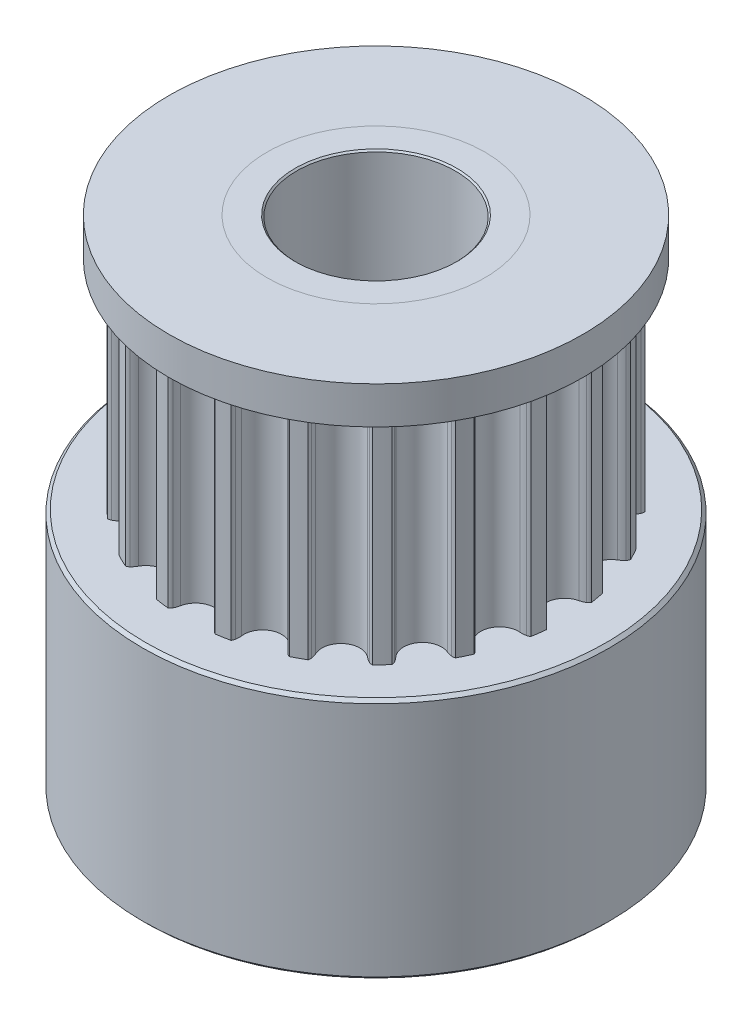
from build123d import *

# Parameters (mm, degrees)
P_IDAT_START            = 7.8
SKICA1_R                = 2.5
P_IDAT_VYSUNUT_M1_DEPTH = 7
SKICA2_R                = 3.5
SKICA2_R_2              = 2.5
P_IDAT_VYSUNUT_M2_DEPTH = 7.8
SKICA3_R                = 3.5
SKICA3_R_2              = 2.5
P_IDAT_VYSUNUT_M3_DEPTH = 1.2
SKICA5_R                = 7.5
SKICA5_R_2              = 3.5
P_IDAT_VYSUNUT_M4_DEPTH = 1.2
SKICA6_R                = 7.5
SKICA6_R_2              = 3.5
P_IDAT_VYSUNUT_M5_DEPTH = 7.8
ZKOSEN_1_SIZE           = 0.1
ZKOSEN_2_SIZE           = 0.1
ZKOSEN_3_SIZE           = 0.1
SKETCH8_OUTSIDE_W       = 22.314
SKETCH8_OUTSIDE_H       = 22.314
SKETCH8_OUTSIDE_R       = 6.65
CUT_EXTRUDE2_DEPTH      = 5
SKETCH19_R              = 1.5
CUT_EXTRUDE6_DEPTH      = 8
SKETCH20_R              = 1.5
CUT_EXTRUDE7_DEPTH      = 8
SKETCH21_R              = 2.55
CUT_EXTRUDE8_DEPTH      = 30


with BuildPart() as part:
    # Skica1 → Přidat vysunutím1 (new body)
    with BuildSketch(Plane(origin=(0, 0, 0), x_dir=(1, 0, 0), z_dir=(0, 1, 0)).offset(P_IDAT_START)):
        with BuildLine():
            ThreePointArc((-5.730143195, 1.098270155), (-5.09645097, 1.530497044), (-5.387174672, 2.240331989))
            ThreePointArc((-5.387174672, 2.240331989), (-5.468060657, 2.292707421), (-5.540463547, 2.356296335))
            ThreePointArc((-5.540463547, 2.356296335), (-5.573874331, 2.399596558), (-5.596043873, 2.44959357))
            ThreePointArc((-5.596043873, 2.44959357), (-5.50369925, 2.650567912), (-5.404139771, 2.848067596))
            ThreePointArc((-5.404139771, 2.848067596), (-5.351227535, 2.86190541), (-5.296542742, 2.862779021))
            ThreePointArc((-5.296542742, 2.862779021), (-5.201685094, 2.845815675), (-5.110305882, 2.815228615))
            ThreePointArc((-5.110305882, 2.815228615), (-4.374063308, 3.030479148), (-4.431206919, 3.795410862))
            ThreePointArc((-4.431206919, 3.795410862), (-4.491949163, 3.870218002), (-4.541158349, 3.953068377))
            ThreePointArc((-4.541158349, 3.953068377), (-4.559553388, 4.004573836), (-4.565187949, 4.058974585))
            ThreePointArc((-4.565187949, 4.058974585), (-4.415258506, 4.221576484), (-4.259541056, 4.378644275))
            ThreePointArc((-4.259541056, 4.378644275), (-4.204942409, 4.375454038), (-4.15266412, 4.359386362))
            ThreePointArc((-4.15266412, 4.359386362), (-4.067691098, 4.313940635), (-3.990236225, 4.256612884))
            ThreePointArc((-3.990236225, 4.256612884), (-3.223511854, 4.233816838), (-3.041481758, 4.978968476))
            ThreePointArc((-3.041481758, 4.978968476), (-3.076134388, 5.06888468), (-3.097332931, 5.162886543))
            ThreePointArc((-3.097332931, 5.162886543), (-3.09891159, 5.217555525), (-3.08745962, 5.271034888))
            ThreePointArc((-3.08745962, 5.271034888), (-2.894621497, 5.379347737), (-2.697988784, 5.480608745))
            ThreePointArc((-2.697988784, 5.480608745), (-2.647048223, 5.460702739), (-2.6022938, 5.429266591))
            ThreePointArc((-2.6022938, 5.429266591), (-2.535523156, 5.359787029), (-2.479574443, 5.281330225))
            ThreePointArc((-2.479574443, 5.281330225), (-1.7574206, 5.022719037), (-1.354035171, 5.675149965))
            ThreePointArc((-1.354035171, 5.675149965), (-1.359206146, 5.771373608), (-1.350318985, 5.867325402))
            ThreePointArc((-1.350318985, 5.867325402), (-1.334926735, 5.919806527), (-1.307509232, 5.967129569))
            ThreePointArc((-1.307509232, 5.967129569), (-1.090638767, 6.010550954), (-0.872338572, 6.046093045))
            ThreePointArc((-0.872338572, 6.046093045), (-0.830042514, 6.01141981), (-0.797192832, 5.967692379))
            ThreePointArc((-0.797192832, 5.967692379), (-0.755160541, 5.880980125), (-0.726194639, 5.789074167))
            ThreePointArc((-0.726194639, 5.789074167), (-0.119300773, 5.319962501), (0.465953812, 5.815808234))
            ThreePointArc((0.465953812, 5.815808234), (0.490770664, 5.908920276), (0.528873591, 5.997429571))
            ThreePointArc((0.528873591, 5.997429571), (0.55973005, 6.04258562), (0.600429269, 6.079120034))
            ThreePointArc((0.600429269, 6.079120034), (0.820103284, 6.053399565), (1.038702217, 6.019743632))
            ThreePointArc((1.038702217, 6.019743632), (1.06821354, 5.973697225), (1.085942924, 5.921958857))
            ThreePointArc((1.085942924, 5.921958857), (1.099122448, 5.826501911), (1.098270155, 5.730143195))
            ThreePointArc((1.098270155, 5.730143195), (1.530497044, 5.09645097), (2.240331989, 5.387174672))
            ThreePointArc((2.240331989, 5.387174672), (2.292707421, 5.468060657), (2.356296335, 5.540463547))
            ThreePointArc((2.356296335, 5.540463547), (2.399596558, 5.573874331), (2.44959357, 5.596043873))
            ThreePointArc((2.44959357, 5.596043873), (2.650567912, 5.50369925), (2.848067596, 5.404139771))
            ThreePointArc((2.848067596, 5.404139771), (2.86190541, 5.351227535), (2.862779021, 5.296542742))
            ThreePointArc((2.862779021, 5.296542742), (2.845815675, 5.201685094), (2.815228615, 5.110305882))
            ThreePointArc((2.815228615, 5.110305882), (3.030479148, 4.374063308), (3.795410862, 4.431206919))
            ThreePointArc((3.795410862, 4.431206919), (3.870218002, 4.491949163), (3.953068377, 4.541158349))
            ThreePointArc((3.953068377, 4.541158349), (4.004573836, 4.559553388), (4.058974585, 4.565187949))
            ThreePointArc((4.058974585, 4.565187949), (4.221576484, 4.415258506), (4.378644275, 4.259541056))
            ThreePointArc((4.378644275, 4.259541056), (4.375454038, 4.204942409), (4.359386362, 4.15266412))
            ThreePointArc((4.359386362, 4.15266412), (4.313940635, 4.067691098), (4.256612884, 3.990236225))
            ThreePointArc((4.256612884, 3.990236225), (4.233816838, 3.223511854), (4.978968476, 3.041481758))
            ThreePointArc((4.978968476, 3.041481758), (5.06888468, 3.076134388), (5.162886543, 3.097332931))
            ThreePointArc((5.162886543, 3.097332931), (5.217555525, 3.09891159), (5.271034888, 3.08745962))
            ThreePointArc((5.271034888, 3.08745962), (5.379347737, 2.894621497), (5.480608745, 2.697988784))
            ThreePointArc((5.480608745, 2.697988784), (5.460702739, 2.647048223), (5.429266591, 2.6022938))
            ThreePointArc((5.429266591, 2.6022938), (5.359787029, 2.535523156), (5.281330225, 2.479574443))
            ThreePointArc((5.281330225, 2.479574443), (5.022719037, 1.7574206), (5.675149965, 1.354035171))
            ThreePointArc((5.675149965, 1.354035171), (5.771373608, 1.359206146), (5.867325402, 1.350318985))
            ThreePointArc((5.867325402, 1.350318985), (5.919806527, 1.334926735), (5.967129569, 1.307509232))
            ThreePointArc((5.967129569, 1.307509232), (6.010550954, 1.090638767), (6.046093045, 0.872338572))
            ThreePointArc((6.046093045, 0.872338572), (6.01141981, 0.830042514), (5.967692379, 0.797192832))
            ThreePointArc((5.967692379, 0.797192832), (5.880980125, 0.755160541), (5.789074167, 0.726194639))
            ThreePointArc((5.789074167, 0.726194639), (5.319962501, 0.119300773), (5.815808234, -0.465953812))
            ThreePointArc((5.815808234, -0.465953812), (5.908920276, -0.490770664), (5.997429571, -0.528873591))
            ThreePointArc((5.997429571, -0.528873591), (6.04258562, -0.55973005), (6.079120034, -0.600429269))
            ThreePointArc((6.079120034, -0.600429269), (6.053399565, -0.820103284), (6.019743632, -1.038702217))
            ThreePointArc((6.019743632, -1.038702217), (5.973697225, -1.06821354), (5.921958857, -1.085942924))
            ThreePointArc((5.921958857, -1.085942924), (5.826501911, -1.099122448), (5.730143195, -1.098270155))
            ThreePointArc((5.730143195, -1.098270155), (5.09645097, -1.530497044), (5.387174672, -2.240331989))
            ThreePointArc((5.387174672, -2.240331989), (5.468060657, -2.292707421), (5.540463547, -2.356296335))
            ThreePointArc((5.540463547, -2.356296335), (5.573874331, -2.399596558), (5.596043873, -2.44959357))
            ThreePointArc((5.596043873, -2.44959357), (5.50369925, -2.650567911), (5.404139771, -2.848067596))
            ThreePointArc((5.404139771, -2.848067596), (5.351227535, -2.86190541), (5.296542742, -2.862779021))
            ThreePointArc((5.296542742, -2.862779021), (5.201685094, -2.845815675), (5.110305882, -2.815228615))
            ThreePointArc((5.110305882, -2.815228615), (4.374063308, -3.030479148), (4.431206919, -3.795410862))
            ThreePointArc((4.431206919, -3.795410862), (4.491949163, -3.870218002), (4.541158349, -3.953068377))
            ThreePointArc((4.541158349, -3.953068377), (4.559553388, -4.004573836), (4.565187949, -4.058974585))
            ThreePointArc((4.565187949, -4.058974585), (4.415258506, -4.221576484), (4.259541056, -4.378644275))
            ThreePointArc((4.259541056, -4.378644275), (4.204942409, -4.375454038), (4.15266412, -4.359386362))
            ThreePointArc((4.15266412, -4.359386362), (4.067691098, -4.313940635), (3.990236225, -4.256612884))
            ThreePointArc((3.990236225, -4.256612884), (3.223511854, -4.233816838), (3.041481758, -4.978968476))
            ThreePointArc((3.041481758, -4.978968476), (3.076134388, -5.06888468), (3.097332931, -5.162886543))
            ThreePointArc((3.097332931, -5.162886543), (3.09891159, -5.217555525), (3.08745962, -5.271034888))
            ThreePointArc((3.08745962, -5.271034888), (2.894621497, -5.379347737), (2.697988784, -5.480608745))
            ThreePointArc((2.697988784, -5.480608745), (2.647048223, -5.460702739), (2.6022938, -5.429266591))
            ThreePointArc((2.6022938, -5.429266591), (2.535523156, -5.359787029), (2.479574443, -5.281330225))
            ThreePointArc((2.479574443, -5.281330225), (1.7574206, -5.022719037), (1.354035171, -5.675149965))
            ThreePointArc((1.354035171, -5.675149965), (1.359206146, -5.771373608), (1.350318985, -5.867325402))
            ThreePointArc((1.350318985, -5.867325402), (1.334926735, -5.919806527), (1.307509232, -5.967129569))
            ThreePointArc((1.307509232, -5.967129569), (1.090638767, -6.010550954), (0.872338572, -6.046093045))
            ThreePointArc((0.872338572, -6.046093045), (0.830042514, -6.01141981), (0.797192832, -5.967692379))
            ThreePointArc((0.797192832, -5.967692379), (0.755160541, -5.880980125), (0.726194639, -5.789074167))
            ThreePointArc((0.726194639, -5.789074167), (0.119300773, -5.319962501), (-0.465953812, -5.815808234))
            ThreePointArc((-0.465953812, -5.815808234), (-0.490770664, -5.908920276), (-0.528873591, -5.997429571))
            ThreePointArc((-0.528873591, -5.997429571), (-0.55973005, -6.04258562), (-0.600429269, -6.079120034))
            ThreePointArc((-0.600429269, -6.079120034), (-0.820103284, -6.053399565), (-1.038702217, -6.019743632))
            ThreePointArc((-1.038702217, -6.019743632), (-1.06821354, -5.973697225), (-1.085942924, -5.921958857))
            ThreePointArc((-1.085942924, -5.921958857), (-1.099122448, -5.826501911), (-1.098270155, -5.730143195))
            ThreePointArc((-1.098270155, -5.730143195), (-1.530497044, -5.09645097), (-2.240331989, -5.387174672))
            ThreePointArc((-2.240331989, -5.387174672), (-2.292707421, -5.468060657), (-2.356296335, -5.540463547))
            ThreePointArc((-2.356296335, -5.540463547), (-2.399596558, -5.573874331), (-2.44959357, -5.596043873))
            ThreePointArc((-2.44959357, -5.596043873), (-2.650567912, -5.50369925), (-2.848067596, -5.404139771))
            ThreePointArc((-2.848067596, -5.404139771), (-2.86190541, -5.351227535), (-2.862779021, -5.296542742))
            ThreePointArc((-2.862779021, -5.296542742), (-2.845815675, -5.201685094), (-2.815228615, -5.110305882))
            ThreePointArc((-2.815228615, -5.110305882), (-3.030479148, -4.374063308), (-3.795410862, -4.431206919))
            ThreePointArc((-3.795410862, -4.431206919), (-3.870218002, -4.491949163), (-3.953068377, -4.541158349))
            ThreePointArc((-3.953068377, -4.541158349), (-4.004573836, -4.559553388), (-4.058974585, -4.565187949))
            ThreePointArc((-4.058974585, -4.565187949), (-4.221576484, -4.415258506), (-4.378644275, -4.259541056))
            ThreePointArc((-4.378644275, -4.259541056), (-4.375454038, -4.204942409), (-4.359386362, -4.15266412))
            ThreePointArc((-4.359386362, -4.15266412), (-4.313940635, -4.067691098), (-4.256612884, -3.990236225))
            ThreePointArc((-4.256612884, -3.990236225), (-4.233816838, -3.223511854), (-4.978968476, -3.041481758))
            ThreePointArc((-4.978968476, -3.041481758), (-5.06888468, -3.076134388), (-5.162886543, -3.097332931))
            ThreePointArc((-5.162886543, -3.097332931), (-5.217555525, -3.09891159), (-5.271034888, -3.08745962))
            ThreePointArc((-5.271034888, -3.08745962), (-5.379347737, -2.894621497), (-5.480608745, -2.697988784))
            ThreePointArc((-5.480608745, -2.697988784), (-5.460702739, -2.647048223), (-5.429266591, -2.6022938))
            ThreePointArc((-5.429266591, -2.6022938), (-5.359787029, -2.535523156), (-5.281330225, -2.479574443))
            ThreePointArc((-5.281330225, -2.479574443), (-5.022719037, -1.7574206), (-5.675149965, -1.354035171))
            ThreePointArc((-5.675149965, -1.354035171), (-5.771373608, -1.359206146), (-5.867325402, -1.350318985))
            ThreePointArc((-5.867325402, -1.350318985), (-5.919806527, -1.334926735), (-5.967129569, -1.307509232))
            ThreePointArc((-5.967129569, -1.307509232), (-6.010550954, -1.090638767), (-6.046093045, -0.872338572))
            ThreePointArc((-6.046093045, -0.872338572), (-6.01141981, -0.830042514), (-5.967692379, -0.797192832))
            ThreePointArc((-5.967692379, -0.797192832), (-5.880980125, -0.755160541), (-5.789074167, -0.726194639))
            ThreePointArc((-5.789074167, -0.726194639), (-5.319962501, -0.119300773), (-5.815808234, 0.465953812))
            ThreePointArc((-5.815808234, 0.465953812), (-5.908920276, 0.490770664), (-5.997429571, 0.528873591))
            ThreePointArc((-5.997429571, 0.528873591), (-6.04258562, 0.55973005), (-6.079120034, 0.600429269))
            ThreePointArc((-6.079120034, 0.600429269), (-6.053399565, 0.820103284), (-6.019743632, 1.038702217))
            ThreePointArc((-6.019743632, 1.038702217), (-5.973697225, 1.06821354), (-5.921958857, 1.085942924))
            ThreePointArc((-5.921958857, 1.085942924), (-5.826501911, 1.099122448), (-5.730143195, 1.098270155))
        make_face()
        Circle(SKICA1_R, mode=Mode.SUBTRACT)
    extrude(amount=P_IDAT_VYSUNUT_M1_DEPTH)

    # Skica2 → Přidat vysunutím2 (add)
    with BuildSketch(Plane.XZ.offset(-7.8)):
        Circle(SKICA2_R)
        Circle(SKICA2_R_2, mode=Mode.SUBTRACT)
    extrude(amount=P_IDAT_VYSUNUT_M2_DEPTH)

    # Skica3 → Přidat vysunutím3 (add)
    with BuildSketch(Plane(origin=(0, 14.8, 0), x_dir=(1, 0, 0), z_dir=(0, 1, 0))):
        Circle(SKICA3_R)
        Circle(SKICA3_R_2, mode=Mode.SUBTRACT)
    extrude(amount=P_IDAT_VYSUNUT_M3_DEPTH)

    # Zkosení2
    zkosen_2_edges = [part.edges().sort_by_distance(p)[0] for p in [
        (-2.5, 0, 0),
        (-2.5, 16, 0),
    ]]
    chamfer(zkosen_2_edges, length=ZKOSEN_2_SIZE)


with BuildPart() as body_2:
    # Skica5 → Přidat vysunutím4 (new body)
    with BuildSketch(Plane(origin=(0, 16, 0), x_dir=(1, 0, 0), z_dir=(0, 1, 0))):
        Circle(SKICA5_R)
        Circle(SKICA5_R_2, mode=Mode.SUBTRACT)
    extrude(amount=-P_IDAT_VYSUNUT_M4_DEPTH)

    # Zkosení1
    zkosen_1_edges = [body_2.edges().sort_by_distance(p)[0] for p in [
        (-7.5, 16, 0),
        (-7.5, 14.8, 0),
    ]]
    chamfer(zkosen_1_edges, length=ZKOSEN_1_SIZE)

    # Sketch8 outside → Cut-Extrude2 (cut)
    with BuildSketch(Plane(origin=(0, 16, 0), x_dir=(1, 0, 0), z_dir=(0, 1, 0))):
        Rectangle(SKETCH8_OUTSIDE_W, SKETCH8_OUTSIDE_H)
        Circle(SKETCH8_OUTSIDE_R, mode=Mode.SUBTRACT)
    extrude(amount=-CUT_EXTRUDE2_DEPTH, mode=Mode.SUBTRACT)


with BuildPart() as body_3:
    # Skica6 → Přidat vysunutím5 (new body)
    with BuildSketch(Plane.XZ):
        Circle(SKICA6_R)
        Circle(SKICA6_R_2, mode=Mode.SUBTRACT)
    extrude(amount=-P_IDAT_VYSUNUT_M5_DEPTH)

    # Zkosení3
    zkosen_3_edges = [body_3.edges().sort_by_distance(p)[0] for p in [
        (-7.5, 0, 0),
        (-7.5, 7.8, 0),
    ]]
    chamfer(zkosen_3_edges, length=ZKOSEN_3_SIZE)


with BuildPart() as cut_extrude6_tool:
    # Sketch19 → Cut-Extrude6 (new body)
    with BuildSketch(Plane(origin=(0, 0, -7.5), x_dir=(-1, 0, 0), z_dir=(0, 0, -1))):
        with Locations((0, 3.9)):
            Circle(SKETCH19_R)
    extrude(amount=-CUT_EXTRUDE6_DEPTH)


with BuildPart() as part_1:
    add(part.part)

    # Cut-Extrude6: cut by cut_extrude6_tool
    add(cut_extrude6_tool.part, mode=Mode.SUBTRACT)


with BuildPart() as body_3_1:
    add(body_3.part)

    # Cut-Extrude6: cut by cut_extrude6_tool
    add(cut_extrude6_tool.part, mode=Mode.SUBTRACT)


with BuildPart() as cut_extrude7_tool:
    # Sketch20 → Cut-Extrude7 (new body)
    with BuildSketch(Plane.ZY.offset(7.5)):
        with Locations((0, 3.9)):
            Circle(SKETCH20_R)
    extrude(amount=-CUT_EXTRUDE7_DEPTH)


with BuildPart() as part_2:
    add(part_1.part)

    # Cut-Extrude7: cut by cut_extrude7_tool
    add(cut_extrude7_tool.part, mode=Mode.SUBTRACT)

    # Sketch21 → Cut-Extrude8 (cut)
    with BuildSketch(Plane(origin=(0, 16, 0), x_dir=(1, 0, 0), z_dir=(0, 1, 0))):
        Circle(SKETCH21_R)
    extrude(amount=-CUT_EXTRUDE8_DEPTH, mode=Mode.SUBTRACT)


with BuildPart() as body_3_2:
    add(body_3_1.part)

    # Cut-Extrude7: cut by cut_extrude7_tool
    add(cut_extrude7_tool.part, mode=Mode.SUBTRACT)


solid = Compound([body_2.part, part_2.part, body_3_2.part])
